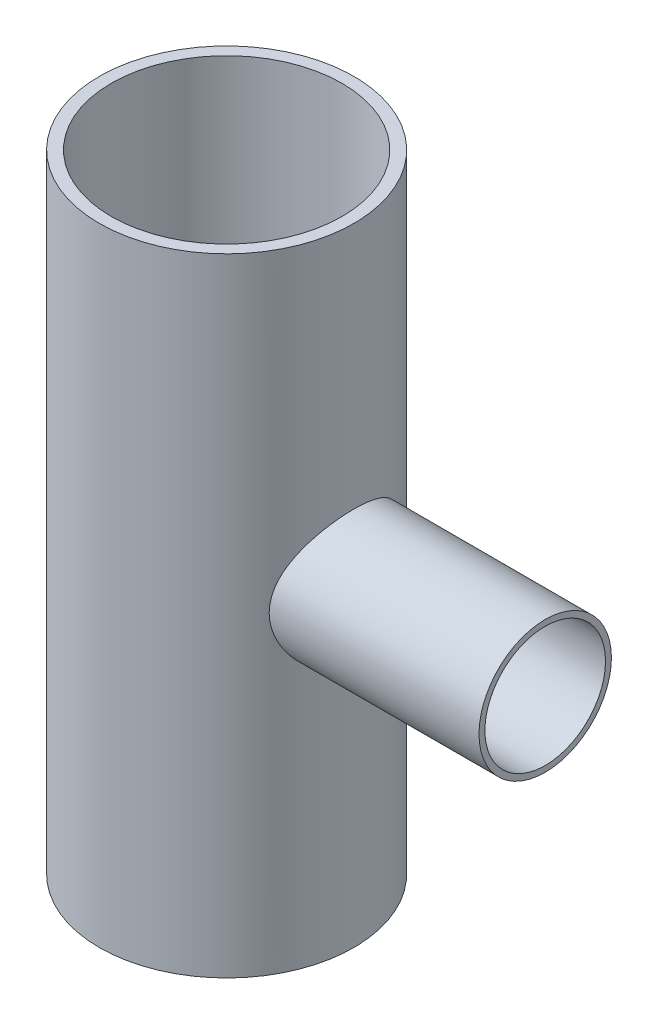
from build123d import *

# Parameters (mm, degrees)
SKETCH1_R           = 161.925
BOSS_EXTRUDE1_DEPTH = 797.56
SKETCH2_R           = 84.201
BOSS_EXTRUDE2_DEPTH = 405.13
SKETCH3_R           = 146.7485
CUT_EXTRUDE1_DEPTH  = 798.5600001
CUT_EXTRUDE2_REACH  = 569.055
SKETCH4_R           = 76.6953


with BuildPart() as part:
    # Sketch1 → Boss-Extrude1 (new body)
    with BuildSketch(Plane(origin=(0, 0, 0), x_dir=(1, 0, 0), z_dir=(0, 1, 0))):
        Circle(SKETCH1_R)
    extrude(amount=BOSS_EXTRUDE1_DEPTH)

    # Sketch2 → Boss-Extrude2 (add)
    with BuildSketch(Plane(origin=(0, 0, 0), x_dir=(0, 0, -1), z_dir=(1, 0, 0))):
        with Locations((0, 398.78)):
            Circle(SKETCH2_R)
    extrude(amount=BOSS_EXTRUDE2_DEPTH)

    # Sketch3 → Cut-Extrude1 (cut, through all)
    with BuildSketch(Plane.XZ):
        Circle(SKETCH3_R)
    extrude(amount=-CUT_EXTRUDE1_DEPTH, mode=Mode.SUBTRACT)

    # Sketch4 → Cut-Extrude2 (cut, up to next)
    with BuildSketch(Plane(origin=(405.13, 0, 0), x_dir=(0, 0, -1), z_dir=(1, 0, 0)), mode=Mode.PRIVATE) as cut_extrude2_sk1:
        with Locations((0, 398.78)):
            Circle(SKETCH4_R)
    cut_extrude2_tool1 = extrude(cut_extrude2_sk1.sketch, amount=-CUT_EXTRUDE2_REACH, mode=Mode.PRIVATE) & part.part
    add(cut_extrude2_tool1.solids().sort_by_distance((405.13, 398.78, 0))[0], mode=Mode.SUBTRACT)


solid = part.part
